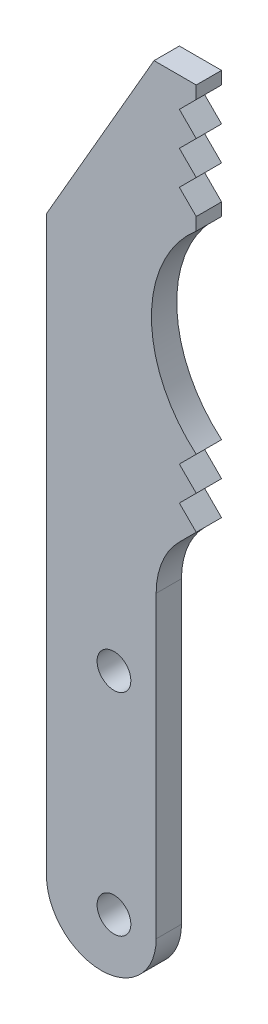
from build123d import *

# Parameters (mm, degrees)
SKETCH1_R           = 2
BOSS_EXTRUDE1_DEPTH = 1.5


with BuildPart() as part:
    # Sketch1 → Boss-Extrude1 (new body, symmetric)
    with BuildSketch(Plane.XY):
        with BuildLine():
            Line((0, 88.5), (-2, 86.5))
            Line((-2, 86.5), (0, 84.5))
            Line((0, 84.5), (-2, 82.5))
            Line((-2, 82.5), (0, 80.5))
            Line((0, 80.5), (-2, 78.5))
            Line((-2, 78.5), (0, 76.5))
            Line((0, 76.5), (0, 75))
            ThreePointArc((0, 75), (-5.309927761, 63.55), (0, 52.1))
            Line((0, 52.1), (-2, 50.1))
            Line((-2, 50.1), (0, 48.1))
            Line((0, 48.1), (-2, 46.1))
            Line((-2, 46.1), (0, 44.1))
            Line((0, 44.1), (-2, 42.1))
            ThreePointArc((-2, 42.1), (-4.035298286, 39.053960857), (-4.75, 35.460912703))
            Line((-4.75, 35.460912703), (-4.75, 0))
            ThreePointArc((-4.75, 0), (-11.25, -6.5), (-17.75, 0))
            Line((-17.75, 0), (-17.75, 67.916352203))
            Line((-17.75, 67.916352203), (-5, 90))
            Line((-5, 90), (0, 90))
            Line((0, 90), (0, 88.5))
        make_face()
        with Locations((-9.75, 0)):
            Circle(SKETCH1_R, mode=Mode.SUBTRACT)
        with Locations((-9.75, 25)):
            Circle(SKETCH1_R, mode=Mode.SUBTRACT)
    extrude(amount=BOSS_EXTRUDE1_DEPTH, both=True)


solid = part.part
